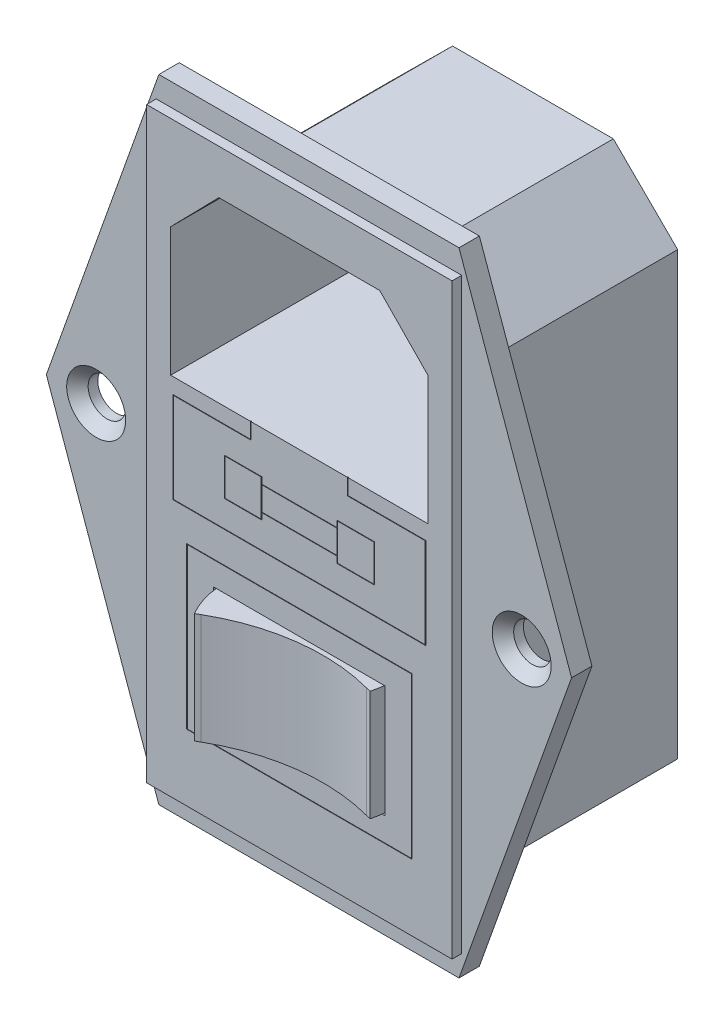
from build123d import *

# Parameters (mm, degrees)
SKETCH1_R           = 1.75
BOSS_EXTRUDE1_DEPTH = 1.9
SKETCH2_W           = 28.5
SKETCH2_H           = 54.8
BOSS_EXTRUDE2_DEPTH = 0.9
CHAMFER1_SIZE       = 1
BOSS_EXTRUDE3_DEPTH = 19
CUT_EXTRUDE1_DEPTH  = 18.3
SKETCH5_W           = 3.5
SKETCH5_H           = 3.5
SKETCH5_W_2         = 3.4
SKETCH5_H_2         = 3.4
SKETCH5_W_3         = 7
SKETCH5_H_3         = 0.05
SKETCH5_W_4         = 21
SKETCH5_H_4         = 15
SKETCH5_W_5         = 20.9
SKETCH5_H_5         = 14.9
CUT_EXTRUDE2_DEPTH  = 0.05
SKETCH6_W           = 24
SKETCH6_H           = 15.5
CUT_EXTRUDE3_DEPTH  = 19
CUT_EXTRUDE4_DEPTH  = 1.25
SKETCH8_W           = 20
SKETCH8_H           = 13
BOSS_EXTRUDE4_DEPTH = 14
SKETCH5_3_W         = 16
SKETCH5_3_H         = 10.5
CUT_EXTRUDE6_DEPTH  = 1
SKETCH10_W          = 7.9
SKETCH10_H          = 10.3
REVOLVE2_ANGLE      = 30
SKETCH10_6_W        = 7.9
SKETCH10_6_H        = 10.3
REVOLVE3_ANGLE      = 15
FILLET1_R           = 18


with BuildPart() as part:
    # Sketch1 → Boss-Extrude1 (new body)
    with BuildSketch(Plane.XY):
        Polygon((-24.5, 0), (-14, 29.5), (14, 29.5), (24.5, 0), (14, -29.5), (-14, -29.5), align=None)
        with Locations((-19.85, 0)):
            Circle(SKETCH1_R, mode=Mode.SUBTRACT)
        with Locations((19.85, 0)):
            Circle(SKETCH1_R, mode=Mode.SUBTRACT)
    extrude(amount=BOSS_EXTRUDE1_DEPTH)

    # Sketch2 → Boss-Extrude2 (add)
    with BuildSketch(Plane.XY.offset(1.9)):
        Rectangle(SKETCH2_W, SKETCH2_H)
    extrude(amount=BOSS_EXTRUDE2_DEPTH)

    # Chamfer1
    chamfer1_edges = [part.edges().sort_by_distance(p)[0] for p in [
        (-21.6, 0, 1.9),
        (18.1, 0, 1.9),
    ]]
    chamfer(chamfer1_edges, length=CHAMFER1_SIZE)

    # Sketch3 → Boss-Extrude3 (add)
    with BuildSketch(Plane(origin=(0, 0, 0), x_dir=(-1, 0, 0), z_dir=(0, 0, -1))):
        Polygon((7.5, 24.6), (-7.5, 24.6), (-13.5, 18.65), (-13.5, -22.5), (13.5, -22.5), (13.5, 18.65), align=None)
    extrude(amount=BOSS_EXTRUDE3_DEPTH)

    # Sketch4 → Cut-Extrude1 (cut)
    with BuildSketch(Plane.XY.offset(2.8)):
        Polygon((7.5, 23.25), (-7.5, 23.25), (-12, 18.65), (-12, 6.65), (12, 6.65), (12, 18.65), align=None)
    extrude(amount=-CUT_EXTRUDE1_DEPTH, mode=Mode.SUBTRACT)

    # Sketch5 → Cut-Extrude2 (cut)
    with BuildSketch(Plane.XY.offset(2.8)):
        with Locations((-5.25, 0.95)):
            Rectangle(SKETCH5_W, SKETCH5_H)
        with Locations((-5.25, 0.95)):
            Rectangle(SKETCH5_W_2, SKETCH5_H_2, mode=Mode.SUBTRACT)
        Polygon((-3.5, 2.05), (0, 2.05), (3.5, 2.05), (3.5, 2.1), (0, 2.1), (-3.5, 2.1), align=None)
        with Locations((0, -0.175)):
            Rectangle(SKETCH5_W_3, SKETCH5_H_3)
        with Locations((5.25, 0.95)):
            Rectangle(SKETCH5_W, SKETCH5_H)
        with Locations((5.25, 0.95)):
            Rectangle(SKETCH5_W_2, SKETCH5_H_2, mode=Mode.SUBTRACT)
        with Locations((0, -13.7)):
            Rectangle(SKETCH5_W_4, SKETCH5_H_4)
        with Locations((0, -13.7)):
            Rectangle(SKETCH5_W_5, SKETCH5_H_5, mode=Mode.SUBTRACT)
        Polygon((-4.5, 6.65), (-4.5, 5.15), (-11.75, 5.15), (-11.75, -3.25), (11.75, -3.25), (11.75, 5.15), (4.5, 5.15), (4.5, 6.65), (4.55, 6.65), (4.55, 5.2), (11.8, 5.2), (11.8, -3.3), (-11.8, -3.3), (-11.8, 5.2), (-4.55, 5.2), (-4.55, 6.65), align=None)
    extrude(amount=-CUT_EXTRUDE2_DEPTH, mode=Mode.SUBTRACT)

    # Sketch6 → Cut-Extrude3 (cut)
    with BuildSketch(Plane(origin=(0, 0, -19), x_dir=(-1, 0, 0), z_dir=(0, 0, -1))):
        with Locations((0, -13.5)):
            Rectangle(SKETCH6_W, SKETCH6_H)
    extrude(amount=-CUT_EXTRUDE3_DEPTH, mode=Mode.SUBTRACT)

    # Sketch7 → Cut-Extrude4 (cut)
    with BuildSketch(Plane.XZ.offset(22.5)):
        Polygon((8.5, -19), (4.458548116, -12), (-4.458548116, -12), (-8.5, -19), align=None)
    extrude(amount=-CUT_EXTRUDE4_DEPTH, mode=Mode.SUBTRACT)

    # Sketch8 → Boss-Extrude4 (add)
    with BuildSketch(Plane(origin=(0, 0, 0), x_dir=(-1, 0, 0), z_dir=(0, 0, -1))):
        with Locations((0, -13.5)):
            Rectangle(SKETCH8_W, SKETCH8_H)
    extrude(amount=BOSS_EXTRUDE4_DEPTH)

    # Sketch5_3 → Cut-Extrude6 (cut)
    with BuildSketch(Plane.XY.offset(2.8)):
        with Locations((0, -13.7)):
            Rectangle(SKETCH5_3_W, SKETCH5_3_H)
    extrude(amount=-CUT_EXTRUDE6_DEPTH, mode=Mode.SUBTRACT)

    # Sketch10 → Revolve2 (revolve)
    with BuildSketch(Plane.XY.offset(1.8)):
        with Locations((-3.95, -13.7)):
            Rectangle(SKETCH10_W, SKETCH10_H)
    revolve(axis=Axis((0, -8.45, 1.8), (0, 1, 0)), revolution_arc=REVOLVE2_ANGLE)

    # Sketch10_6 → Revolve3 (revolve)
    with BuildSketch(Plane.XY.offset(1.8)):
        with Locations((3.95, -13.7)):
            Rectangle(SKETCH10_6_W, SKETCH10_6_H)
    revolve(axis=Axis((0, -8.45, 1.8), (0, -1, 0)), revolution_arc=REVOLVE3_ANGLE)

    # Fillet1
    fillet1_edges = [part.edges().sort_by_distance(p)[0] for p in [
        (0, -13.7, 1.8),
    ]]
    fillet(fillet1_edges, radius=FILLET1_R)


solid = part.part
